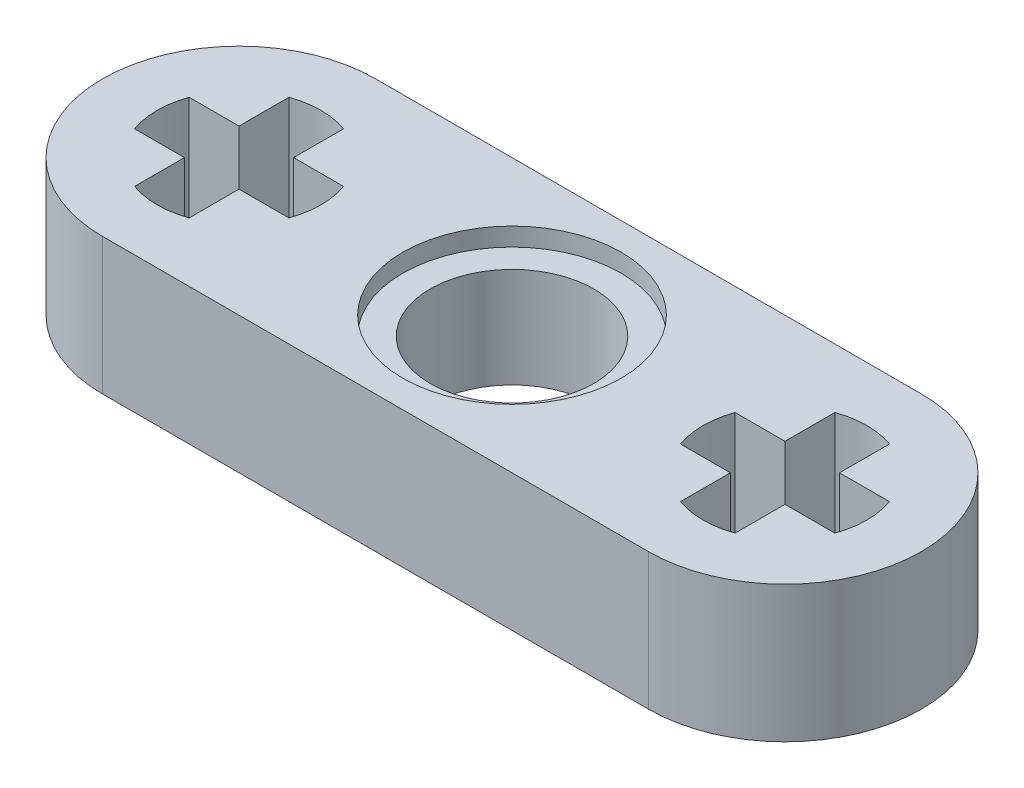
from build123d import *

# Parameters (mm, degrees)
SKETCH1_R           = 1.5
BOSS_EXTRUDE1_DEPTH = 1.25
SKETCH1_3_R         = 2
SKETCH1_3_R_2       = 1.5
CUT_EXTRUDE1_DEPTH  = 0.333333333


with BuildPart() as part:
    # Sketch1 → Boss-Extrude1 (new body)
    with BuildSketch(Plane(origin=(0, 0, 0), x_dir=(1, 0, 0), z_dir=(0, 1, 0))):
        with BuildLine():
            Line((5, 2.5), (-5, 2.5))
            ThreePointArc((-5, 2.5), (-7.5, 0), (-5, -2.5))
            Line((-5, -2.5), (5.000000022, -2.5))
            ThreePointArc((5.000000022, -2.5), (7.5, 1.1e-08), (5, 2.5))
        make_face()
        with BuildLine():
            Line((4.5, 0.5), (4.5, 1.414213562))
            ThreePointArc((4.5, 1.414213562), (5, 1.5), (5.5, 1.414213562))
            Line((5.5, 1.414213562), (5.5, 0.5))
            Line((5.5, 0.5), (6.414213562, 0.5))
            ThreePointArc((6.414213562, 0.5), (6.5, 0), (6.414213562, -0.5))
            Line((6.414213562, -0.5), (5.5, -0.5))
            Line((5.5, -0.5), (5.5, -1.414213562))
            ThreePointArc((5.5, -1.414213562), (5, -1.5), (4.5, -1.414213562))
            Line((4.5, -1.414213562), (4.5, -0.5))
            Line((4.5, -0.5), (3.585786438, -0.5))
            ThreePointArc((3.585786438, -0.5), (3.5, 0), (3.585786438, 0.5))
            Line((3.585786438, 0.5), (4.5, 0.5))
        make_face(mode=Mode.SUBTRACT)
        Circle(SKETCH1_R, mode=Mode.SUBTRACT)
        with BuildLine():
            Line((-5.5, -1.414213562), (-5.5, -0.5))
            Line((-5.5, -0.5), (-6.414213562, -0.5))
            ThreePointArc((-6.414213562, -0.5), (-6.5, 0), (-6.414213562, 0.5))
            Line((-6.414213562, 0.5), (-5.5, 0.5))
            Line((-5.5, 0.5), (-5.5, 1.414213562))
            ThreePointArc((-5.5, 1.414213562), (-5, 1.5), (-4.5, 1.414213562))
            Line((-4.5, 1.414213562), (-4.5, 0.5))
            Line((-4.5, 0.5), (-3.585786438, 0.5))
            ThreePointArc((-3.585786438, 0.5), (-3.5, 0), (-3.585786438, -0.5))
            Line((-3.585786438, -0.5), (-4.5, -0.5))
            Line((-4.5, -0.5), (-4.5, -1.414213562))
            ThreePointArc((-4.5, -1.414213562), (-5, -1.5), (-5.5, -1.414213562))
        make_face(mode=Mode.SUBTRACT)
    boss_extrude1 = extrude(amount=BOSS_EXTRUDE1_DEPTH)

    # Sketch1_3 → Cut-Extrude1 (cut)
    with BuildSketch(Plane(origin=(0, 0, 0), x_dir=(1, 0, 0), z_dir=(0, 1, 0))):
        Circle(SKETCH1_3_R)
        Circle(SKETCH1_3_R_2, mode=Mode.SUBTRACT)
    cut_extrude1 = extrude(amount=CUT_EXTRUDE1_DEPTH, mode=Mode.SUBTRACT)

    # Mirror1: Boss-Extrude1, Cut-Extrude1 across plane
    add(boss_extrude1.mirror(Plane.ZX.offset(1.25)))
    add(cut_extrude1.mirror(Plane.ZX.offset(1.25)), mode=Mode.SUBTRACT)


solid = part.part
